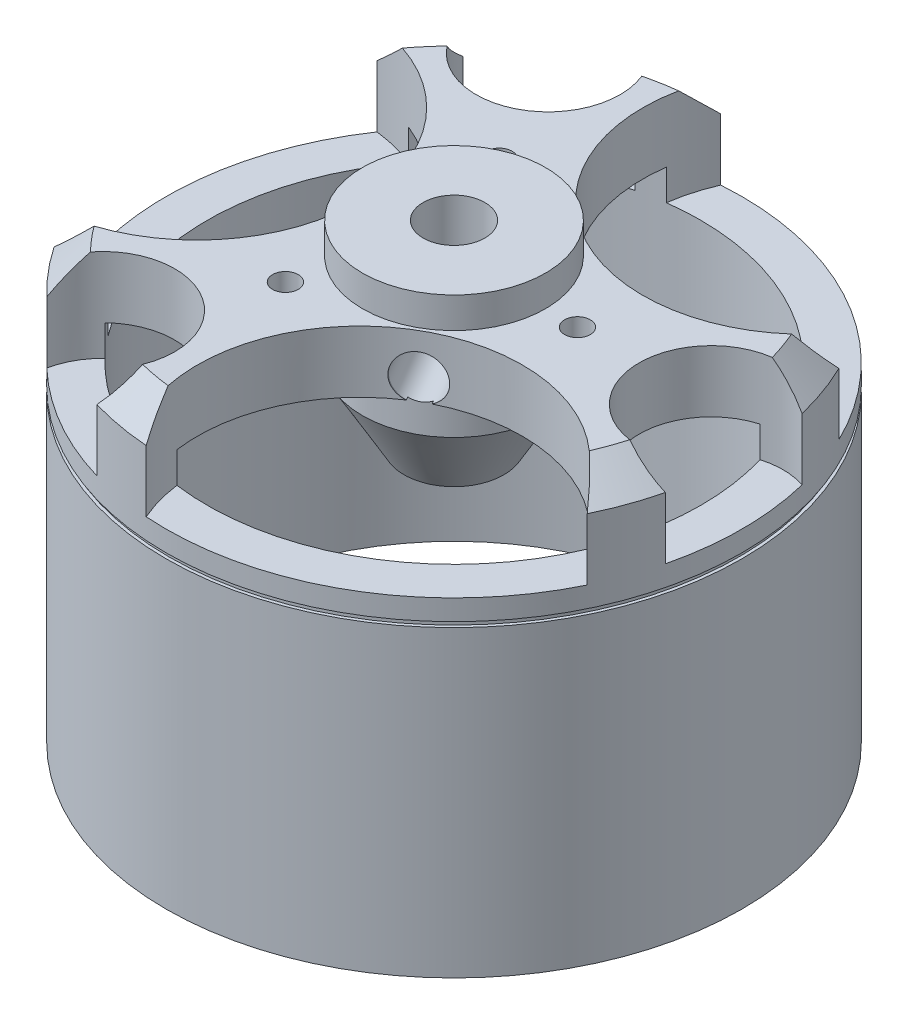
from build123d import *

# Parameters (mm, degrees)
SKETCH1_R                          = 14
BOSS_EXTRUDE1_DEPTH                = 20.5
SKETCH2_R                          = 12
CUT_EXTRUDE1_DEPTH                 = 17.5
CHAMFER1_SIZE                      = 1.5
SKETCH3_W                          = 0.15
SKETCH3_H                          = 0.25
SKETCH4_R                          = 4.45
BOSS_EXTRUDE2_DEPTH                = 1.5
BOSS_EXTRUDE2_DEPTH_BACK           = 4.5
SKETCH10_R                         = 4.45
BOSS_EXTRUDE3_DEPTH                = 3.5
BOSS_EXTRUDE3_TAPER                = 30
SKETCH5_R                          = 1.5
CUT_EXTRUDE2_DEPTH                 = 23
CUT_EXTRUDE3_DEPTH                 = 4.5
M1_6X0_35_TAPPED_HOLE1_D           = 1.25
M1_6X0_35_TAPPED_HOLE1_DEPTH       = 4.25
M1_6X0_35_TAPPED_HOLE1_TIP         = 0.375537887
M2_CLEARANCE_HOLE4_D               = 2.2
M2_CLEARANCE_HOLE4_DEPTH           = 3.5
M2_CLEARANCE_HOLE4_TIP             = 0.660946681
M2_CLEARANCE_HOLE4_ON_FACE_2_D     = 2.2
M2_CLEARANCE_HOLE4_ON_FACE_2_DEPTH = 3.5
M2_CLEARANCE_HOLE4_ON_FACE_2_TIP   = 0.660946681


with BuildPart() as part:
    # Sketch1 → Boss-Extrude1 (new body)
    with BuildSketch(Plane(origin=(0, 0, 0), x_dir=(1, 0, 0), z_dir=(0, 1, 0))):
        Circle(SKETCH1_R)
    extrude(amount=BOSS_EXTRUDE1_DEPTH)

    # Sketch2 → Cut-Extrude1 (cut)
    with BuildSketch(Plane.XZ):
        Circle(SKETCH2_R)
    extrude(amount=-CUT_EXTRUDE1_DEPTH, mode=Mode.SUBTRACT)

    # Chamfer1
    chamfer1_edges = [part.edges().sort_by_distance(p)[0] for p in [
        (-14, 20.5, 0),
    ]]
    chamfer(chamfer1_edges, length=CHAMFER1_SIZE)

    # Sketch3 → Cut-Revolve1 (revolve, cut)
    with BuildSketch(Plane(origin=(0, 0, 0), x_dir=(0, 0, -1), z_dir=(1, 0, 0))):
        with Locations((13.925, 14.875)):
            Rectangle(SKETCH3_W, SKETCH3_H)
    revolve(axis=Axis((0, 20.5, 0), (0, -1, 0)), mode=Mode.SUBTRACT)

    # Sketch4 → Boss-Extrude2 (add, two sides)
    with BuildSketch(Plane(origin=(0, 20.5, 0), x_dir=(1, 0, 0), z_dir=(0, 1, 0))) as boss_extrude2_sk:
        Circle(SKETCH4_R)
    extrude(amount=BOSS_EXTRUDE2_DEPTH)
    extrude(boss_extrude2_sk.sketch, amount=-BOSS_EXTRUDE2_DEPTH_BACK)

    # Sketch10 → Boss-Extrude3 (add)
    with BuildSketch(Plane.XZ.offset(-16)):
        Circle(SKETCH10_R)
    extrude(amount=BOSS_EXTRUDE3_DEPTH, taper=BOSS_EXTRUDE3_TAPER)

    # Sketch5 → Cut-Extrude2 (cut, through all)
    with BuildSketch(Plane(origin=(0, 22, 0), x_dir=(1, 0, 0), z_dir=(0, 1, 0))):
        Circle(SKETCH5_R)
    extrude(amount=-CUT_EXTRUDE2_DEPTH, mode=Mode.SUBTRACT)

    # Sketch6 → Cut-Extrude3 (cut)
    with BuildSketch(Plane(origin=(0, 20.5, 0), x_dir=(1, 0, 0), z_dir=(0, 1, 0))):
        with BuildLine():
            ThreePointArc((-10.0036, -7.495197598), (-4.6, 0), (-10.0036, 7.495197598))
            ThreePointArc((-10.0036, 7.495197598), (-12.5, 0), (-10.0036, -7.495197598))
        make_face()
        with BuildLine():
            ThreePointArc((-10.0036, 7.495197598), (-10.789488556, 7.712596878), (-11.5936, 7.847830212))
            ThreePointArc((-11.5936, 7.847830212), (-14, 0), (-11.5936, -7.847830212))
            ThreePointArc((-11.5936, -7.847830212), (-10.789488556, -7.712596878), (-10.0036, -7.495197598))
            ThreePointArc((-10.0036, -7.495197598), (-12.5, 0), (-10.0036, 7.495197598))
        make_face()
        with BuildLine():
            ThreePointArc((-9.006237245, -8.668199968), (-6.25, -10.825317547), (-3.003762755, -12.133730231))
            ThreePointArc((-3.003762755, -12.133730231), (-4.5, -7.794228634), (-9.006237245, -8.668199968))
        make_face()
        with BuildLine():
            ThreePointArc((-9.677498914, -10.116620719), (-7, -12.124355653), (-3.922501086, -13.439270264))
            ThreePointArc((-3.922501086, -13.439270264), (-3.387703302, -12.839581088), (-3.003762755, -12.133730231))
            ThreePointArc((-3.003762755, -12.133730231), (-6.25, -10.825317547), (-9.006237245, -8.668199968))
            ThreePointArc((-9.006237245, -8.668199968), (-9.425551745, -9.353627664), (-9.677498914, -10.116620719))
        make_face()
        with BuildLine():
            ThreePointArc((-0.999620328, -13.964267227), (7, -12.124355653), (12.593220328, -6.116437015))
            ThreePointArc((12.593220328, -6.116437015), (12.074049103, -5.487672744), (11.492831527, -4.91577293))
            ThreePointArc((11.492831527, -4.91577293), (6.25, -10.825317547), (-1.489231527, -12.410970529))
            ThreePointArc((-1.489231527, -12.410970529), (-1.284560547, -13.200269622), (-0.999620328, -13.964267227))
        make_face()
        with BuildLine():
            ThreePointArc((-1.489231527, -12.410970529), (6.25, -10.825317547), (11.492831527, -4.91577293))
            ThreePointArc((11.492831527, -4.91577293), (2.3, -3.983716857), (-1.489231527, -12.410970529))
        make_face()
        with BuildLine():
            ThreePointArc((12.5, 0), (12.376893794, 1.75), (12.01, 3.465530262))
            ThreePointArc((12.01, 3.465530262), (9, 0), (12.01, -3.465530262))
            ThreePointArc((12.01, -3.465530262), (12.376893794, -1.75), (12.5, 0))
        make_face()
        with BuildLine():
            ThreePointArc((13.6, -3.322649545), (13.899640283, -1.673320053), (14, 0))
            ThreePointArc((14, 0), (13.899640283, 1.673320053), (13.6, 3.322649545))
            ThreePointArc((13.6, 3.322649545), (12.813255048, 3.485953424), (12.01, 3.465530262))
            ThreePointArc((12.01, 3.465530262), (12.376893794, 1.75), (12.5, 0))
            ThreePointArc((12.5, 0), (12.376893794, -1.75), (12.01, -3.465530262))
            ThreePointArc((12.01, -3.465530262), (12.813255048, -3.485953424), (13.6, -3.322649545))
        make_face()
        with BuildLine():
            ThreePointArc((11.492831527, 4.91577293), (12.074049103, 5.487672744), (12.593220328, 6.116437015))
            ThreePointArc((12.593220328, 6.116437015), (7, 12.124355653), (-0.999620328, 13.964267227))
            ThreePointArc((-0.999620328, 13.964267227), (-1.284560547, 13.200269622), (-1.489231527, 12.410970529))
            ThreePointArc((-1.489231527, 12.410970529), (6.25, 10.825317547), (11.492831527, 4.91577293))
        make_face()
        with BuildLine():
            ThreePointArc((-1.489231527, 12.410970529), (2.3, 3.983716857), (11.492831527, 4.91577293))
            ThreePointArc((11.492831527, 4.91577293), (6.25, 10.825317547), (-1.489231527, 12.410970529))
        make_face()
        with BuildLine():
            ThreePointArc((-9.006237245, 8.668199968), (-4.5, 7.794228634), (-3.003762755, 12.133730231))
            ThreePointArc((-3.003762755, 12.133730231), (-6.25, 10.825317547), (-9.006237245, 8.668199968))
        make_face()
        with BuildLine():
            ThreePointArc((-3.003762755, 12.133730231), (-3.387703302, 12.839581088), (-3.922501086, 13.439270264))
            ThreePointArc((-3.922501086, 13.439270264), (-7, 12.124355653), (-9.677498914, 10.116620719))
            ThreePointArc((-9.677498914, 10.116620719), (-9.425551745, 9.353627664), (-9.006237245, 8.668199968))
            ThreePointArc((-9.006237245, 8.668199968), (-6.25, 10.825317547), (-3.003762755, 12.133730231))
        make_face()
    extrude(amount=-CUT_EXTRUDE3_DEPTH, mode=Mode.SUBTRACT)

    # M1.6x0.35 Tapped Hole1
    with Locations(Plane(origin=(6, 20.5, 0), x_dir=(0, 0, 1), z_dir=(0, 1, 0))):
        with Locations((0, 0), (5.196152423, -9), (-5.196152423, -9)):
            Hole(M1_6X0_35_TAPPED_HOLE1_D / 2, depth=M1_6X0_35_TAPPED_HOLE1_DEPTH)
            with Locations((0, 0, -(M1_6X0_35_TAPPED_HOLE1_DEPTH + M1_6X0_35_TAPPED_HOLE1_TIP / 2))):  # 118° drill point
                Cone(0, M1_6X0_35_TAPPED_HOLE1_D / 2, M1_6X0_35_TAPPED_HOLE1_TIP, mode=Mode.SUBTRACT)

    # M2 Clearance Hole4
    with Locations(Plane(origin=(-4.6, 18.5, 0), x_dir=(0, 0, -1), z_dir=(-1, 0, 0))):
        with Locations((0, 0)):
            Hole(M2_CLEARANCE_HOLE4_D / 2, depth=M2_CLEARANCE_HOLE4_DEPTH)
            with Locations((0, 0, -(M2_CLEARANCE_HOLE4_DEPTH + M2_CLEARANCE_HOLE4_TIP / 2))):  # 118° drill point
                Cone(0, M2_CLEARANCE_HOLE4_D / 2, M2_CLEARANCE_HOLE4_TIP, mode=Mode.SUBTRACT)

    # M2 Clearance Hole4 on face 2
    with Locations(Plane(origin=(2.3, 18.5, 3.983716857), x_dir=(0.866025303, 0, -0.500000175), z_dir=(0.500000175, 0, 0.866025303))):
        with Locations((0, 0)):
            Hole(M2_CLEARANCE_HOLE4_ON_FACE_2_D / 2, depth=M2_CLEARANCE_HOLE4_ON_FACE_2_DEPTH)
            with Locations((0, 0, -(M2_CLEARANCE_HOLE4_ON_FACE_2_DEPTH + M2_CLEARANCE_HOLE4_ON_FACE_2_TIP / 2))):  # 118° drill point
                Cone(0, M2_CLEARANCE_HOLE4_ON_FACE_2_D / 2, M2_CLEARANCE_HOLE4_ON_FACE_2_TIP, mode=Mode.SUBTRACT)


solid = part.part
